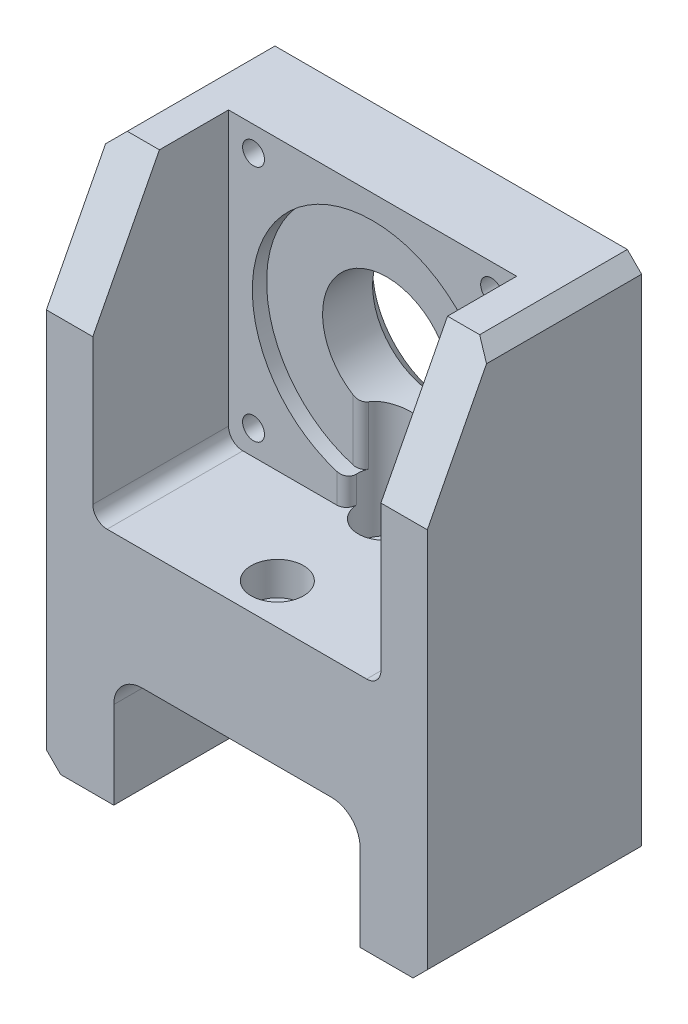
from build123d import *

# Parameters (mm, degrees)
SKETCH1_R               = 13.5
BOSS_EXTRUDE1_DEPTH     = 22.5
SKETCH2_W               = 60.5
SKETCH2_H               = 60.5
CUT_EXTRUDE1_DEPTH      = 28.5
SKETCH3_R               = 25.25
CUT_EXTRUDE2_DEPTH      = 3
SKETCH4_R               = 2.3
CUT_EXTRUDE3_DEPTH      = 29.5
CUT_EXTRUDE3_DEPTH_BACK = 17.5
CHAMFER1_SIZE           = 3
SKETCH5_R               = 3.05
CUT_EXTRUDE4_DEPTH      = 80.75
SKETCH6_R               = 5.5
CUT_EXTRUDE5_DEPTH      = 37.25
FILLET1_R               = 3
FILLET2_R               = 6
FILLET3_R               = 2
CHAMFER2_SIZE           = 3
CUT_EXTRUDE6_DEPTH      = 1
CUT_EXTRUDE6_DEPTH_BACK = 81


with BuildPart() as part:
    # Sketch1 → Boss-Extrude1 (new body, symmetric)
    with BuildSketch(Plane.XY):
        Polygon((40, -79.75), (25.85, -79.75), (25.85, -55.45), (-25.85, -55.45), (-25.85, -79.75), (-40, -79.75), (-40, 30.25), (40, 30.25), align=None)
        Circle(SKETCH1_R, mode=Mode.SUBTRACT)
    extrude(amount=BOSS_EXTRUDE1_DEPTH, both=True)

    # Sketch2 → Cut-Extrude1 (cut)
    with BuildSketch(Plane.XY.offset(22.5)):
        Rectangle(SKETCH2_W, SKETCH2_H)
    extrude(amount=-CUT_EXTRUDE1_DEPTH, mode=Mode.SUBTRACT)

    # Sketch3 → Cut-Extrude2 (cut)
    with BuildSketch(Plane.XY.offset(-6)):
        Circle(SKETCH3_R)
    extrude(amount=-CUT_EXTRUDE2_DEPTH, mode=Mode.SUBTRACT)

    # Sketch4 → Cut-Extrude3 (cut, two sides)
    with BuildSketch(Plane.XY.offset(-6)) as cut_extrude3_sk:
        with Locations((-25, 25)):
            Circle(SKETCH4_R)
        with Locations((25, 25)):
            Circle(SKETCH4_R)
        with Locations((25, -25)):
            Circle(SKETCH4_R)
        with Locations((-25, -25)):
            Circle(SKETCH4_R)
    extrude(amount=CUT_EXTRUDE3_DEPTH, mode=Mode.SUBTRACT)
    extrude(cut_extrude3_sk.sketch, amount=-CUT_EXTRUDE3_DEPTH_BACK, mode=Mode.SUBTRACT)

    # Chamfer1
    chamfer1_edges = [part.edges().sort_by_distance(p)[0] for p in [
        (-13.5, 0, -22.5),
    ]]
    chamfer(chamfer1_edges, length=CHAMFER1_SIZE)

    # Sketch5 → Cut-Extrude4 (cut, through all)
    with BuildSketch(Plane(origin=(0, 0, 0), x_dir=(1, 0, 0), z_dir=(0, 1, 0))):
        with Locations((0, 8.5)):
            Circle(SKETCH5_R)
        with Locations((0, -14)):
            Circle(SKETCH5_R)
    extrude(amount=-CUT_EXTRUDE4_DEPTH, mode=Mode.SUBTRACT)

    # Sketch6 → Cut-Extrude5 (cut)
    with BuildSketch(Plane(origin=(0, 0, 0), x_dir=(1, 0, 0), z_dir=(0, 1, 0))):
        with Locations((0, -14)):
            Circle(SKETCH6_R)
        with Locations((0, 8.5)):
            Circle(SKETCH6_R)
    extrude(amount=-CUT_EXTRUDE5_DEPTH, mode=Mode.SUBTRACT)

    # Fillet1
    fillet1_edges = [part.edges().sort_by_distance(p)[0] for p in [
        (-30.25, -30.25, 8.25),
        (30.25, -30.25, 8.25),
    ]]
    fillet(fillet1_edges, radius=FILLET1_R)

    # Fillet2
    fillet2_edges = [part.edges().sort_by_distance(p)[0] for p in [
        (25.85, -55.45, 0),
        (-25.85, -55.45, 0),
    ]]
    fillet(fillet2_edges, radius=FILLET2_R)

    # Fillet3
    fillet3_edges = [part.edges().sort_by_distance(p)[0] for p in [
        (5.477225575, -18.493872805, -9),
        (-5.477225575, -18.493872805, -9),
        (4.898979486, -27.510096891, -6),
        (-4.898979486, -27.510096891, -6),
    ]]
    fillet(fillet3_edges, radius=FILLET3_R)

    # Chamfer2
    chamfer2_edges = [part.edges().sort_by_distance(p)[0] for p in [
        (-40, 30.25, 0),
        (40, 30.25, 0),
        (40, -79.75, 0),
        (-40, -79.75, 0),
    ]]
    chamfer(chamfer2_edges, length=CHAMFER2_SIZE)

    # Sketch7 → Cut-Extrude6 (cut, two sides)
    with BuildSketch(Plane(origin=(40, 0, 0), x_dir=(0, 0, -1), z_dir=(1, 0, 0))) as cut_extrude6_sk:
        Polygon((-8.512452887, 30.25), (-22.5, 3.260250001), (-22.5, 30.25), align=None)
    extrude(amount=CUT_EXTRUDE6_DEPTH, mode=Mode.SUBTRACT)
    extrude(cut_extrude6_sk.sketch, amount=-CUT_EXTRUDE6_DEPTH_BACK, mode=Mode.SUBTRACT)


solid = part.part
